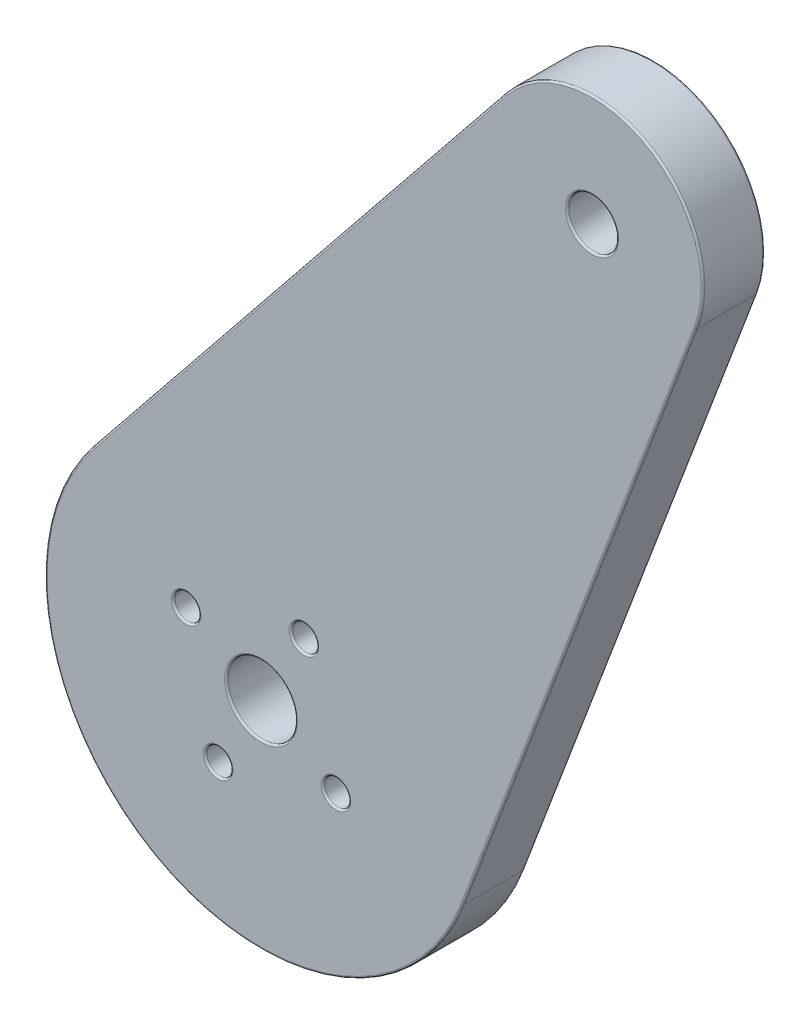
from build123d import *

# Parameters (mm, degrees)
SKETCH1_R           = 2.8
SKETCH1_R_2         = 2
SKETCH1_R_3         = 1.05
BOSS_EXTRUDE1_DEPTH = 5
FILLET1_R           = 0.15


with BuildPart() as part:
    # Sketch1 → Boss-Extrude1 (new body)
    with BuildSketch(Plane.XY):
        with BuildLine():
            Line((-33.848494558, 68.557893062), (-0.396142845, 110.087282233))
            ThreePointArc((-0.396142845, 110.087282233), (11.084930082, 112.251760101), (15.029630952, 101.254517945))
            Line((15.029630952, 101.254517945), (-3.853934396, 51.383073613))
            ThreePointArc((-3.853934396, 51.383073613), (-28.915813912, 42.393399972), (-33.848494558, 68.557893062))
        make_face()
        with Locations((-20.22, 57.58)):
            Circle(SKETCH1_R, mode=Mode.SUBTRACT)
        with Locations((6.612797213, 104.441508658)):
            Circle(SKETCH1_R_2, mode=Mode.SUBTRACT)
        with Locations((-26.294640011, 61.058325565)):
            Circle(SKETCH1_R_3, mode=Mode.SUBTRACT)
        with Locations((-16.741674435, 63.654640011)):
            Circle(SKETCH1_R_3, mode=Mode.SUBTRACT)
        with Locations((-23.698325565, 51.505359989)):
            Circle(SKETCH1_R_3, mode=Mode.SUBTRACT)
        with Locations((-14.145359989, 54.101674435)):
            Circle(SKETCH1_R_3, mode=Mode.SUBTRACT)
    extrude(amount=-BOSS_EXTRUDE1_DEPTH)

    # Fillet1
    fillet1_edges = [part.edges().sort_by_distance(p)[0] for p in [
        (-23.02, 57.58, -5),
        (-23.02, 57.58, 0),
        (11.084930082, 112.251760101, -5),
        (4.612797213, 104.441508658, -5),
        (4.612797213, 104.441508658, 0),
        (-17.122318702, 89.322587648, -5),
        (-27.344640011, 61.058325565, -5),
        (-27.344640011, 61.058325565, 0),
        (-17.791674435, 63.654640011, -5),
        (-17.791674435, 63.654640011, 0),
        (-24.748325565, 51.505359989, -5),
        (-24.748325565, 51.505359989, 0),
        (-15.195359989, 54.101674435, -5),
        (-15.195359989, 54.101674435, 0),
        (-28.915813912, 42.393399972, -5),
        (-17.122318702, 89.322587648, 0),
        (11.084930082, 112.251760101, 0),
        (5.587848278, 76.318795779, 0),
        (-28.915813912, 42.393399972, 0),
        (5.587848278, 76.318795779, -5),
    ]]
    fillet(fillet1_edges, radius=FILLET1_R)


solid = part.part
